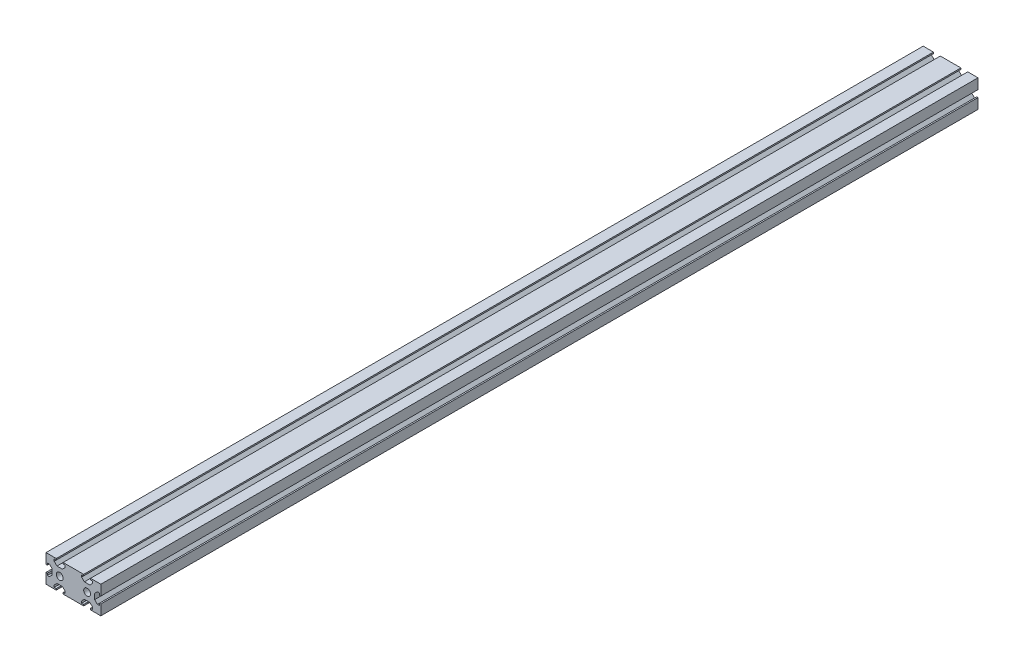
from build123d import *

# Parameters (mm, degrees)
SKETCH_1_W          = 40
SKETCH_1_H          = 20
EXTRUDE_1_DEPTH     = 320
SKETCH_2_R          = 2.5
CUT_EXTRUDE_1_DEPTH = 641


with BuildPart() as part:
    # 草图1 → 凸台-拉伸1 (new body, symmetric)
    with BuildSketch(Plane.XY):
        Rectangle(SKETCH_1_W, SKETCH_1_H)
    extrude(amount=EXTRUDE_1_DEPTH, both=True)

    # 草图2 → 切除-拉伸1 (cut, through all)
    with BuildSketch(Plane(origin=(0, 0, -320), x_dir=(-1, 0, 0), z_dir=(0, 0, -1))):
        with Locations((-10, 0)):
            Circle(SKETCH_2_R)
        with Locations((10, 0)):
            Circle(SKETCH_2_R)
        Polygon((-12.5, 10), (-12.5, 9), (-14, 9), (-14, 7.5), (-12, 5.5), (-8, 5.5), (-6, 7.5), (-6, 9), (-7.5, 9), (-7.5, 10), align=None)
        Polygon((-7.5, -9), (-7.5, -10), (-12.5, -10), (-12.5, -9), (-14, -9), (-14, -7.5), (-12, -5.5), (-8, -5.5), (-6, -7.5), (-6, -9), align=None)
        Polygon((-20, 2.5), (-19, 2.5), (-19, 4), (-17.5, 4), (-15.5, 2), (-15.5, -2), (-17.5, -4), (-19, -4), (-19, -2.5), (-20, -2.5), align=None)
        Polygon((7.5, 9), (7.5, 10), (12.5, 10), (12.5, 9), (14, 9), (14, 7.5), (12, 5.5), (8, 5.5), (6, 7.5), (6, 9), align=None)
        Polygon((6, -9), (7.5, -9), (7.5, -10), (12.5, -10), (12.5, -9), (14, -9), (14, -7.5), (12, -5.5), (8, -5.5), (6, -7.5), align=None)
        Polygon((19, -2.5), (20, -2.5), (20, 2.5), (19, 2.5), (19, 4), (17.5, 4), (15.5, 2), (15.5, -2), (17.5, -4), (19, -4), align=None)
    extrude(amount=-CUT_EXTRUDE_1_DEPTH, mode=Mode.SUBTRACT)


solid = part.part
